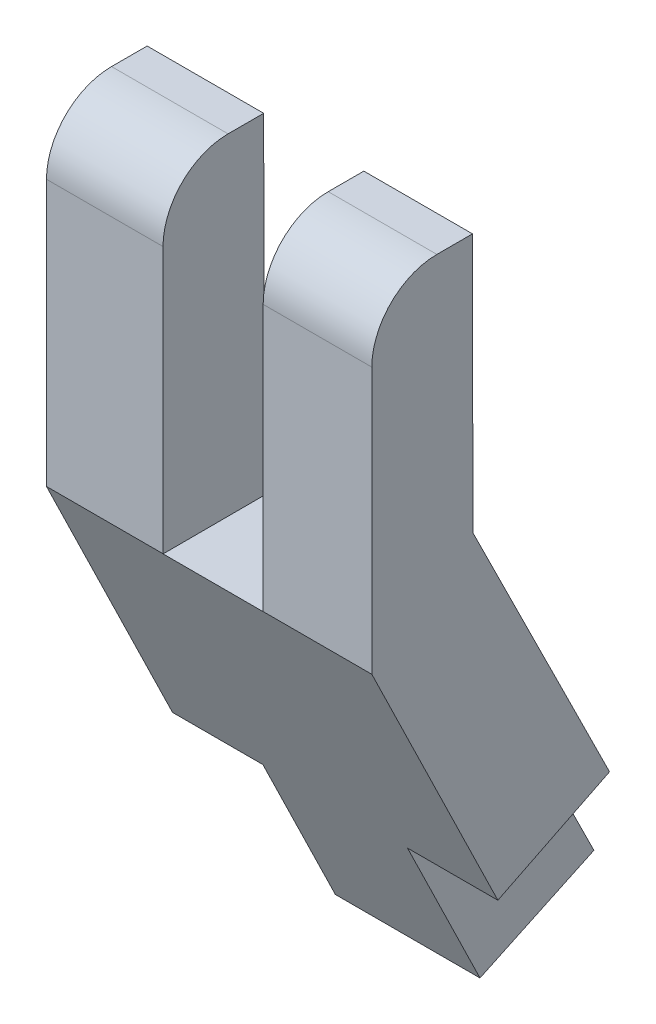
from build123d import *

# Parameters (mm, degrees)
BOSS_EXTRUDE1_DEPTH            = 4.5
CUT_EXTRUDE1_REACH             = 3.412
SKETCH4_W                      = 1.385219638
SKETCH4_H                      = 4.6
CUT_EXTRUDE1_DIRECTION_2_DEPTH = 4.5
FILLET1_R                      = 0.9
CUT_EXTRUDE3_REACH             = 6.201
SKETCH9_W                      = 1.25
SKETCH9_H                      = 2.324916291


with BuildPart() as part:
    # Sketch3 → Boss-Extrude1 (new body)
    with BuildSketch(Plane(origin=(0, 0, 0), x_dir=(0, 0, -1), z_dir=(1, 0, 0))):
        Polygon((-5.191543854, 13.25823412), (-5.18615245, 9.674078564), (-2.262529631, 3.784549229), (-3.838080431, 3.04292615), (-6.584072535, 8.678891581), (-6.584072535, 13.25823412), align=None)
    extrude(amount=BOSS_EXTRUDE1_DEPTH)

    # Sketch4 → Cut-Extrude1 (cut, up to next)
    with BuildSketch(Plane(origin=(0, -0.010796619, 5.165911314), x_dir=(-1, 0, 0), z_dir=(0, 0.002089969, -0.999997816)), mode=Mode.PRIVATE) as cut_extrude1_sk1:
        with Locations((-2.304435674, 10.989683529)):
            Rectangle(SKETCH4_W, SKETCH4_H)
    cut_extrude1_tool1 = extrude(cut_extrude1_sk1.sketch, amount=-CUT_EXTRUDE1_REACH, mode=Mode.PRIVATE) & part.part
    add(cut_extrude1_tool1.solids().sort_by_distance((2.304436, 10.978863, 5.188879))[0], mode=Mode.SUBTRACT)

    # Sketch4 → Cut-Extrude1 direction 2 (cut)
    with BuildSketch(Plane(origin=(0, -0.010796619, 5.165911314), x_dir=(-1, 0, 0), z_dir=(0, 0.002089969, -0.999997816))):
        with Locations((-2.304435674, 10.989683529)):
            Rectangle(SKETCH4_W, SKETCH4_H)
    extrude(amount=CUT_EXTRUDE1_DIRECTION_2_DEPTH, mode=Mode.SUBTRACT)

    # Fillet1
    fillet1_edges = [part.edges().sort_by_distance(p)[0] for p in [
        (3.748522747, 13.25823412, 6.584072535),
        (0.805912927, 13.25823412, 6.584072535),
    ]]
    fillet(fillet1_edges, radius=FILLET1_R)

    # Sketch9 → Cut-Extrude3 (cut, up to next)
    with BuildSketch(Plane(origin=(0, -0.152871347, 0.307953638), x_dir=(-1, 0, 0), z_dir=(0, 0.444639458, -0.895709636)), mode=Mode.PRIVATE) as cut_extrude3_sk1:
        with Locations((-0.625, 5.558325308)):
            Rectangle(SKETCH9_W, SKETCH9_H)
    cut_extrude3_tool1 = extrude(cut_extrude3_sk1.sketch, amount=-CUT_EXTRUDE3_REACH, mode=Mode.PRIVATE) & part.part
    add(cut_extrude3_tool1.solids().sort_by_distance((0.625, 4.825774, 2.779404))[0], mode=Mode.SUBTRACT)
    # Sketch9 → Cut-Extrude3 (cut, up to next)
    with BuildSketch(Plane(origin=(0, -0.152871347, 0.307953638), x_dir=(-1, 0, 0), z_dir=(0, 0.444639458, -0.895709636)), mode=Mode.PRIVATE) as cut_extrude3_sk2:
        with Locations((-3.875, 5.558325308)):
            Rectangle(SKETCH9_W, SKETCH9_H)
    cut_extrude3_tool2 = extrude(cut_extrude3_sk2.sketch, amount=-CUT_EXTRUDE3_REACH, mode=Mode.PRIVATE) & part.part
    add(cut_extrude3_tool2.solids().sort_by_distance((3.875, 4.825774, 2.779404))[0], mode=Mode.SUBTRACT)


solid = part.part
